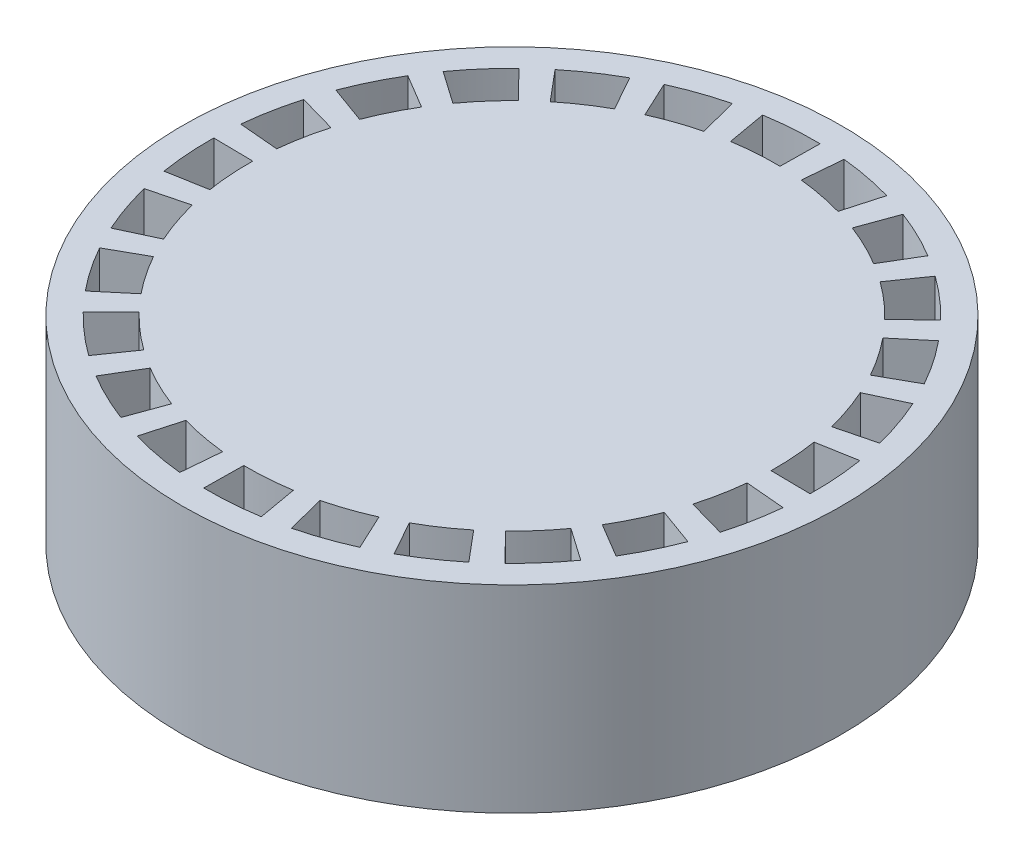
from build123d import *

# Parameters (mm, degrees)
SKETCH1_R           = 31.75
BOSS_EXTRUDE1_DEPTH = 19.05
CUT_EXTRUDE1_DEPTH  = 5.08
CIRPATTERN1_COUNT   = 24


with BuildPart() as part:
    # Sketch1 → Boss-Extrude1 (new body)
    with BuildSketch(Plane(origin=(0, 0, 0), x_dir=(1, 0, 0), z_dir=(0, 1, 0))):
        Circle(SKETCH1_R)
    extrude(amount=BOSS_EXTRUDE1_DEPTH)

    # Sketch2 → Cut-Extrude1 (cut)
    with BuildSketch(Plane(origin=(0, 19.05, 0), x_dir=(1, 0, 0), z_dir=(0, 1, 0))):
        with BuildLine():
            Line((0.431861346, 25.396328392), (0.481566937, 29.206030084))
            ThreePointArc((0.481566937, 29.206030084), (-2.110193645, 29.133677811), (-4.685328245, 28.831784531))
            Line((-4.685328245, 28.831784531), (-4.021364533, 25.079645677))
            ThreePointArc((-4.021364533, 25.079645677), (-1.801722861, 25.336017736), (0.431861346, 25.396328392))
        make_face()
    cut_extrude1 = extrude(amount=-CUT_EXTRUDE1_DEPTH, mode=Mode.SUBTRACT)

    # CirPattern1: Cut-Extrude1 ×24 about axis
    cirpattern1_axis = Axis((0, 0, 0), (0, 1, 0))
    for i in range(1, CIRPATTERN1_COUNT):
        add(cut_extrude1.rotate(cirpattern1_axis, i * 360 / CIRPATTERN1_COUNT), mode=Mode.SUBTRACT)


solid = part.part
